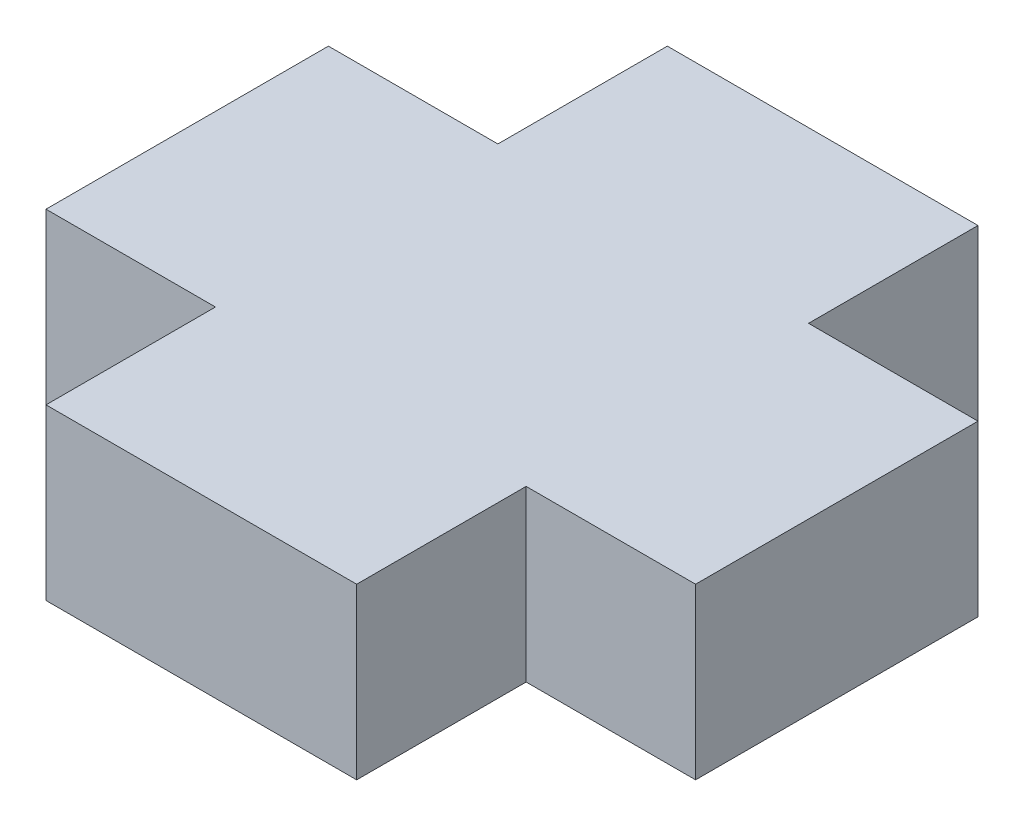
from build123d import *

# Parameters (mm, degrees)
BOSS_EXTRUDE1_DEPTH = 3


with BuildPart() as part:
    # Sketch1 → Boss-Extrude1 (new body)
    with BuildSketch(Plane(origin=(0, 0, 0), x_dir=(1, 0, 0), z_dir=(0, 1, 0))):
        Polygon((-16.22010191, -4.344670155), (-16.22010191, 0.655329845), (-13.22010191, 0.655329845), (-13.22010191, 3.655329845), (-7.72010191, 3.655329845), (-7.72010191, 0.655329845), (-4.72010191, 0.655329845), (-4.72010191, -4.344670155), (-7.72010191, -4.344670155), (-7.72010191, -7.344670155), (-13.22010191, -7.344670155), (-13.22010191, -4.344670155), align=None)
    extrude(amount=BOSS_EXTRUDE1_DEPTH)


solid = part.part
